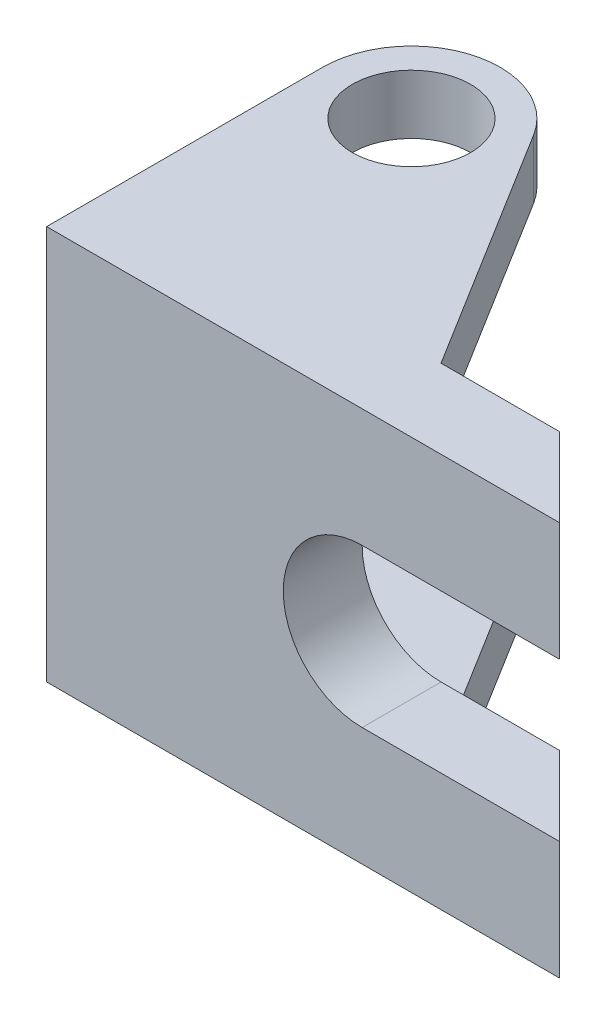
from build123d import *

# Parameters (mm, degrees)
SKETCH1_R               = 15
BOSS_EXTRUDE1_DEPTH     = 100
CUT_EXTRUDE1_DEPTH      = 140.575248522
CUT_EXTRUDE3_DEPTH      = 140.575248522
CUT_EXTRUDE3_DEPTH_BACK = 140.575248522


with BuildPart() as part:
    # Sketch1 → Boss-Extrude1 (new body)
    with BuildSketch(Plane(origin=(0, 0, 0), x_dir=(1, 0, 0), z_dir=(0, 1, 0))):
        with BuildLine():
            ThreePointArc((-23.38084198, 46.862031723), (-48.66720944, 56.638288466), (-65, 35))
            Line((-65, 35), (-65, -35))
            Line((-65, -35), (65, -35))
            Line((65, -35), (45, -15))
            Line((45, -15), (15, -15))
            Line((15, -15), (-23.38084198, 46.862031723))
        make_face()
        with Locations((-42.5, 35)):
            Circle(SKETCH1_R, mode=Mode.SUBTRACT)
    extrude(amount=BOSS_EXTRUDE1_DEPTH)

    # Sketch2 → Cut-Extrude1 (cut, through all)
    with BuildSketch(Plane(origin=(0, 0, 15), x_dir=(-1, 0, 0), z_dir=(0, 0, -1))):
        with BuildLine():
            Line((-45, 85), (-45, 70))
            Line((-45, 70), (-15, 70))
            ThreePointArc((-15, 70), (5, 50), (-15, 30))
            Line((-15, 30), (-45, 30))
            Line((-45, 30), (-45, 15))
            Line((-45, 15), (76.993822349, 15))
            Line((76.993822349, 15), (76.993822349, 85))
            Line((76.993822349, 85), (-45, 85))
        make_face()
    extrude(amount=CUT_EXTRUDE1_DEPTH, mode=Mode.SUBTRACT)

    # Sketch2_3 → Cut-Extrude3 (cut, two sides: drawn at the far end of the back side and taken through both)
    with BuildSketch(Plane(origin=(0, 0, 15), x_dir=(-1, 0, 0), z_dir=(0, 0, -1)).offset(-CUT_EXTRUDE3_DEPTH_BACK)):
        with BuildLine():
            Line((-106.993822349, 70), (-106.993822349, 30))
            Line((-106.993822349, 30), (-15, 30))
            ThreePointArc((-15, 30), (5, 50), (-15, 70))
            Line((-15, 70), (-106.993822349, 70))
        make_face()
    extrude(amount=CUT_EXTRUDE3_DEPTH + CUT_EXTRUDE3_DEPTH_BACK, mode=Mode.SUBTRACT)


solid = part.part
